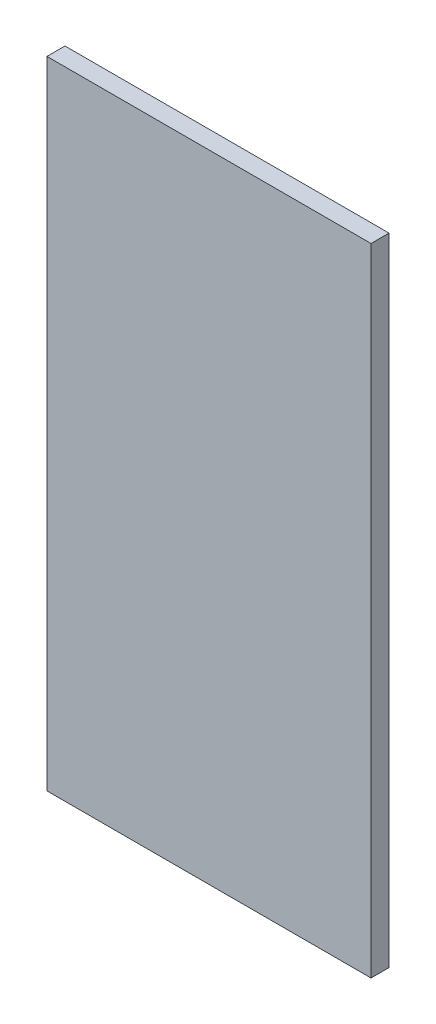
from build123d import *

# Parameters (mm, degrees)
SKETCH1_W           = 270
SKETCH1_H           = 530
BOSS_EXTRUDE1_DEPTH = 15


with BuildPart() as part:
    # Sketch1 → Boss-Extrude1 (new body)
    with BuildSketch(Plane.XY):
        with Locations((135, 265)):
            Rectangle(SKETCH1_W, SKETCH1_H)
    extrude(amount=BOSS_EXTRUDE1_DEPTH)


solid = part.part
